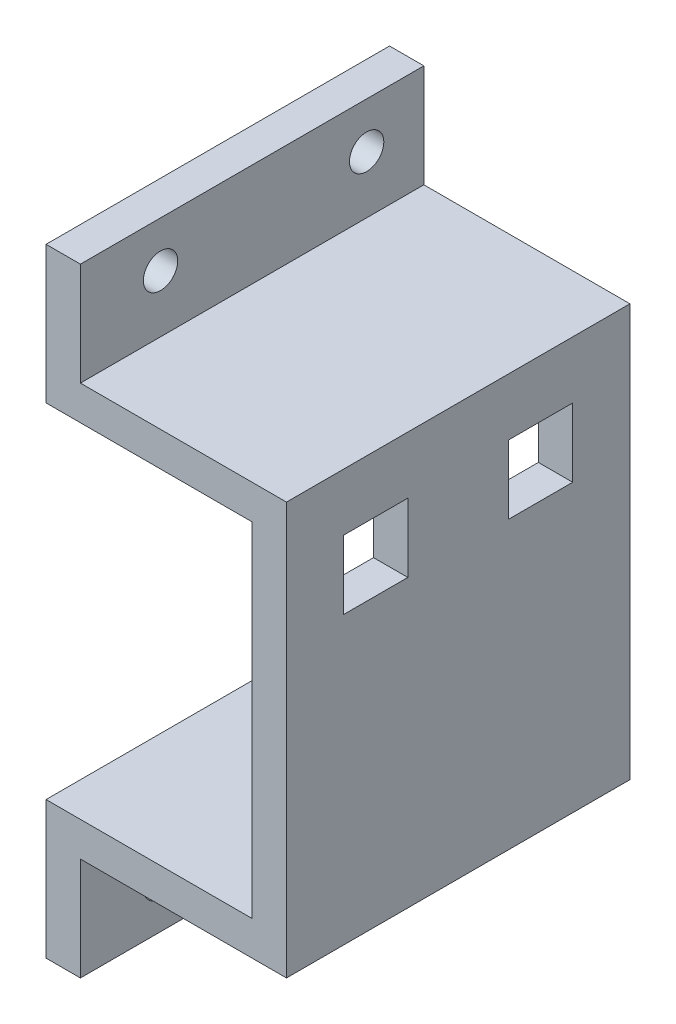
from build123d import *

# Parameters (mm, degrees)
EXTRUDE_1_DEPTH     = 15
SKETCH_2_W          = 5.6
SKETCH_2_H          = 6
CUT_EXTRUDE_1_DEPTH = 20
SKETCH_3_R          = 1.5
CUT_EXTRUDE_2_DEPTH = 10


with BuildPart() as part:
    # 草图1 → 凸台-拉伸1 (new body, symmetric)
    with BuildSketch(Plane.XY):
        Polygon((0, 0), (18, 0), (18, -30), (0, -30), (0, -42), (3, -42), (3, -33), (21, -33), (21, 3), (3, 3), (3, 12), (0, 12), align=None)
    extrude(amount=EXTRUDE_1_DEPTH, both=True)

    # 草图2 → 切除-拉伸1 (cut)
    with BuildSketch(Plane(origin=(21, 0, 0), x_dir=(0, 0, -1), z_dir=(1, 0, 0))):
        with Locations((-7.2, -5)):
            Rectangle(SKETCH_2_W, SKETCH_2_H)
    cut_extrude_1 = extrude(amount=-CUT_EXTRUDE_1_DEPTH, mode=Mode.SUBTRACT)

    # 镜向1: 切除-拉伸1 across plane
    add(cut_extrude_1.mirror(Plane.XY), mode=Mode.SUBTRACT)

    # 草图3 → 切除-拉伸2 (cut)
    with BuildSketch(Plane(origin=(3, 0, 0), x_dir=(0, 0, -1), z_dir=(1, 0, 0))):
        with Locations((10, 8)):
            Circle(SKETCH_3_R)
        with Locations((-8, 8)):
            Circle(SKETCH_3_R)
    cut_extrude_2 = extrude(amount=-CUT_EXTRUDE_2_DEPTH, mode=Mode.SUBTRACT)

    # 镜向2: 切除-拉伸2 across plane
    add(cut_extrude_2.mirror(Plane(origin=(0, -15, 0), x_dir=(0, 0, 1), z_dir=(0, -1, 0))), mode=Mode.SUBTRACT)


solid = part.part
